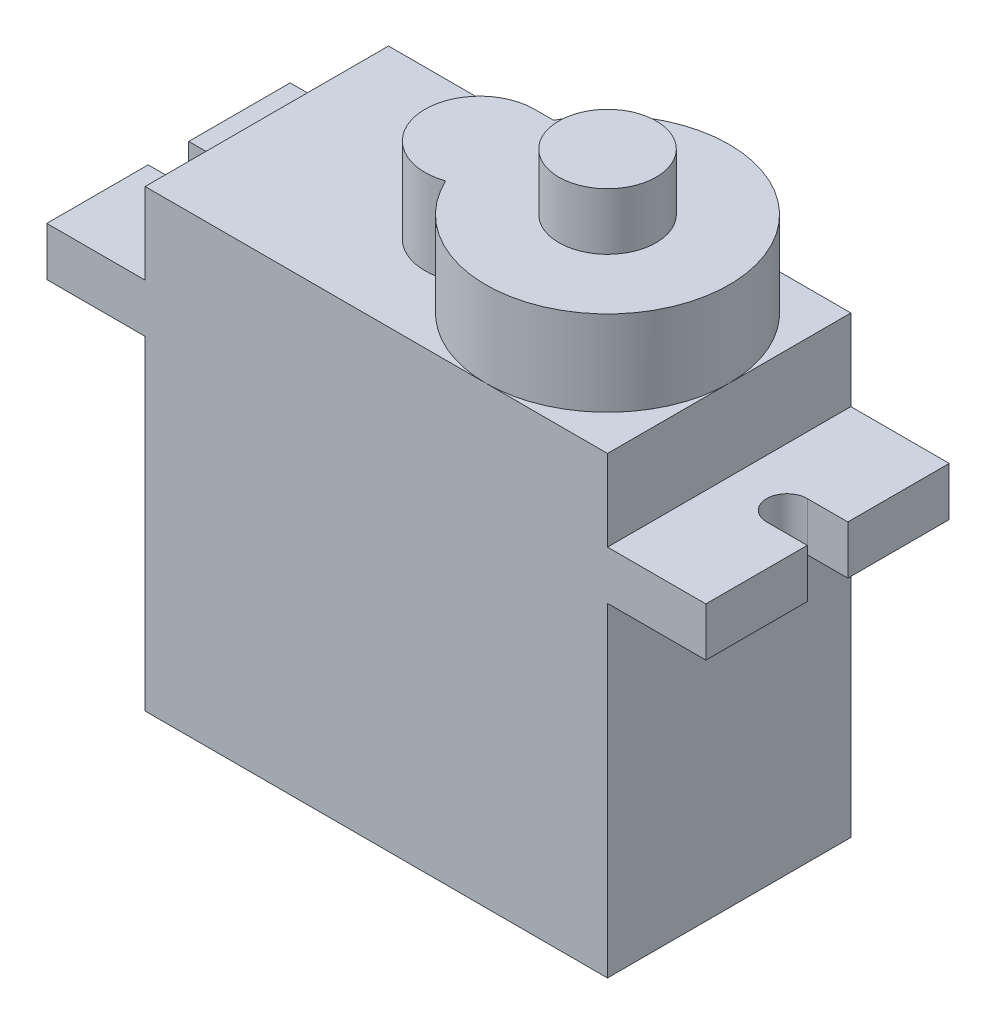
from build123d import *

# Parameters (mm, degrees)
SKETCH1_W           = 22.8
SKETCH1_H           = 16
BOSS_EXTRUDE1_DEPTH = 12
SKETCH2_W           = 32.5
SKETCH2_H           = 12
MOUNTING_DEPTH      = 2.4
SKETCH4_W           = 22.8
SKETCH4_H           = 12
BOSS_EXTRUDE4_DEPTH = 4
SKETCH6_R           = 2.7
SKETCH6_R_2         = 6
BOSS_EXTRUDE5_DEPTH = 4.2
SKETCH7_R           = 2.4
BOSS_EXTRUDE6_DEPTH = 2.8
SKETCH8_R           = 1
CUT_EXTRUDE1_DEPTH  = 2.8
SKETCH9_W           = 10
SKETCH9_H           = 13
CUT_EXTRUDE2_DEPTH  = 1


with BuildPart() as part:
    # Sketch1 → Boss-Extrude1 (new body)
    with BuildSketch(Plane.XY):
        Rectangle(SKETCH1_W, SKETCH1_H)
    extrude(amount=BOSS_EXTRUDE1_DEPTH)

    # Sketch2 → mounting (add)
    with BuildSketch(Plane(origin=(0, 8, 0), x_dir=(1, 0, 0), z_dir=(0, 1, 0))):
        with Locations((0, -6)):
            Rectangle(SKETCH2_W, SKETCH2_H)
    extrude(amount=MOUNTING_DEPTH)

    # Sketch4 → Boss-Extrude4 (add)
    with BuildSketch(Plane(origin=(0, 10.4, 0), x_dir=(1, 0, 0), z_dir=(0, 1, 0))):
        with Locations((0, -6)):
            Rectangle(SKETCH4_W, SKETCH4_H)
    extrude(amount=BOSS_EXTRUDE4_DEPTH)

    # Sketch6 → Boss-Extrude5 (add)
    with BuildSketch(Plane(origin=(0, 14.4, 0), x_dir=(1, 0, 0), z_dir=(0, 1, 0))):
        with Locations((-0.9, -6)):
            Circle(SKETCH6_R)
        with Locations((5.4, -6)):
            Circle(SKETCH6_R_2)
        with BuildLine():
            Line((0.04182867, -3.3), (-0.9, -3.3))
            ThreePointArc((-0.9, -3.3), (-0.458336611, -3.336368372), (-0.028571429, -3.44449374))
            ThreePointArc((-0.028571429, -3.44449374), (0.006144751, -3.37201112), (0.04182867, -3.3))
        make_face()
    extrude(amount=BOSS_EXTRUDE5_DEPTH)

    # Sketch7 → Boss-Extrude6 (add)
    with BuildSketch(Plane(origin=(0, 18.6, 0), x_dir=(1, 0, 0), z_dir=(0, 1, 0))):
        with Locations((5.4, -6)):
            Circle(SKETCH7_R)
    extrude(amount=BOSS_EXTRUDE6_DEPTH)

    # Sketch8 → Cut-Extrude1 (cut)
    with BuildSketch(Plane(origin=(0, 10.4, 0), x_dir=(1, 0, 0), z_dir=(0, 1, 0))):
        with Locations((-14.25, -6)):
            Circle(SKETCH8_R)
        with BuildLine():
            ThreePointArc((-14.25, -7), (-15.25, -6), (-14.25, -5))
            Line((-14.25, -5), (-16.25, -5))
            Line((-16.25, -5), (-16.25, -7))
            Line((-16.25, -7), (-14.25, -7))
        make_face()
        with BuildLine():
            ThreePointArc((15.25, -6), (14.957106781, -6.707106781), (14.25, -7))
            Line((14.25, -7), (16.25, -7))
            Line((16.25, -7), (16.25, -5))
            Line((16.25, -5), (14.25, -5))
            ThreePointArc((14.25, -5), (14.957106781, -5.292893219), (15.25, -6))
        make_face()
        with Locations((14.25, -6)):
            Circle(SKETCH8_R)
    extrude(amount=-CUT_EXTRUDE1_DEPTH, mode=Mode.SUBTRACT)

    # Sketch9 → Cut-Extrude2 (cut)
    with BuildSketch(Plane(origin=(0, 0, 0), x_dir=(-1, 0, 0), z_dir=(0, 0, -1))):
        Rectangle(SKETCH9_W, SKETCH9_H)
    extrude(amount=-CUT_EXTRUDE2_DEPTH, mode=Mode.SUBTRACT)


solid = part.part
